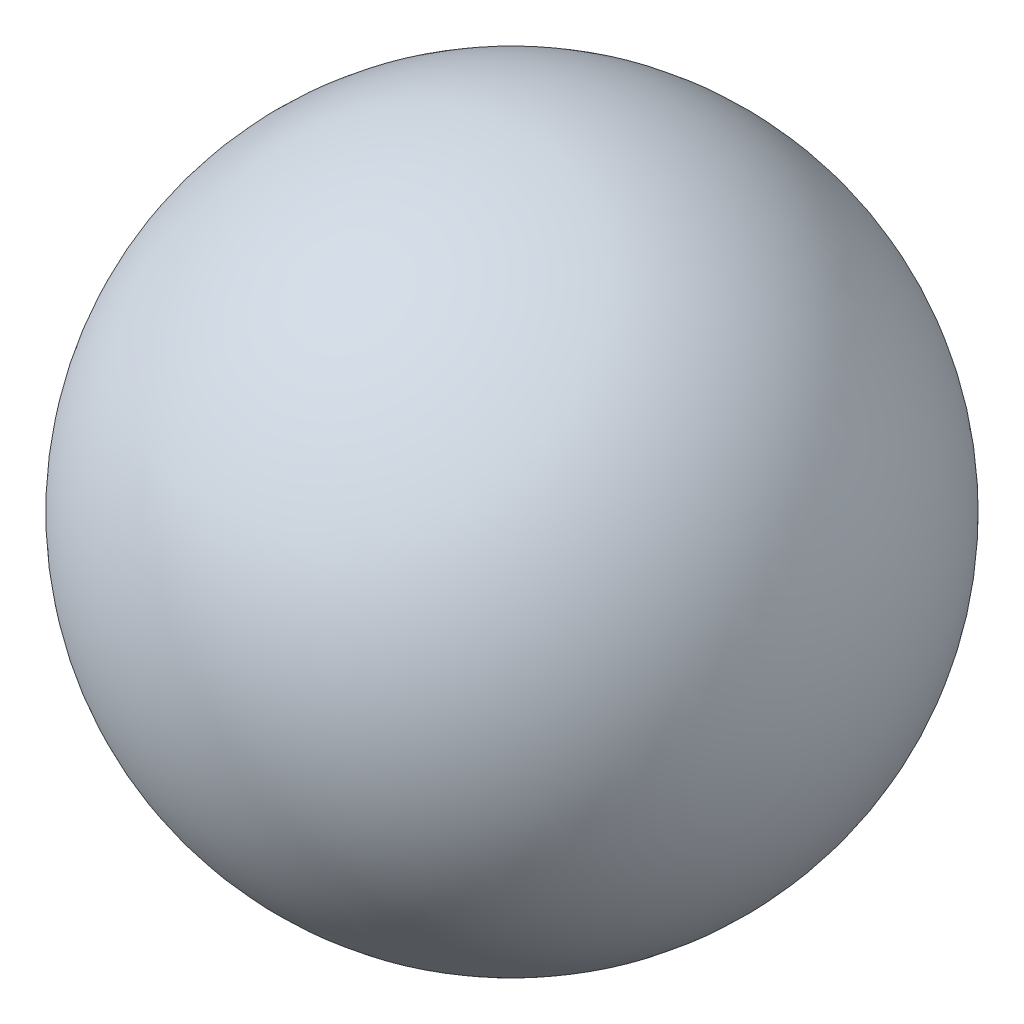
from build123d import *


with BuildPart() as part:
    # ｽｹｯﾁ1 → 回転3 (revolve)
    with BuildSketch(Plane.XY):
        with BuildLine():
            Line((0, 2.5), (0, -2.5))
            ThreePointArc((0, -2.5), (2.5, 0), (0, 2.5))
        make_face()
    revolve(axis=Axis((0, 0, 0), (0, 1, 0)))


solid = part.part
